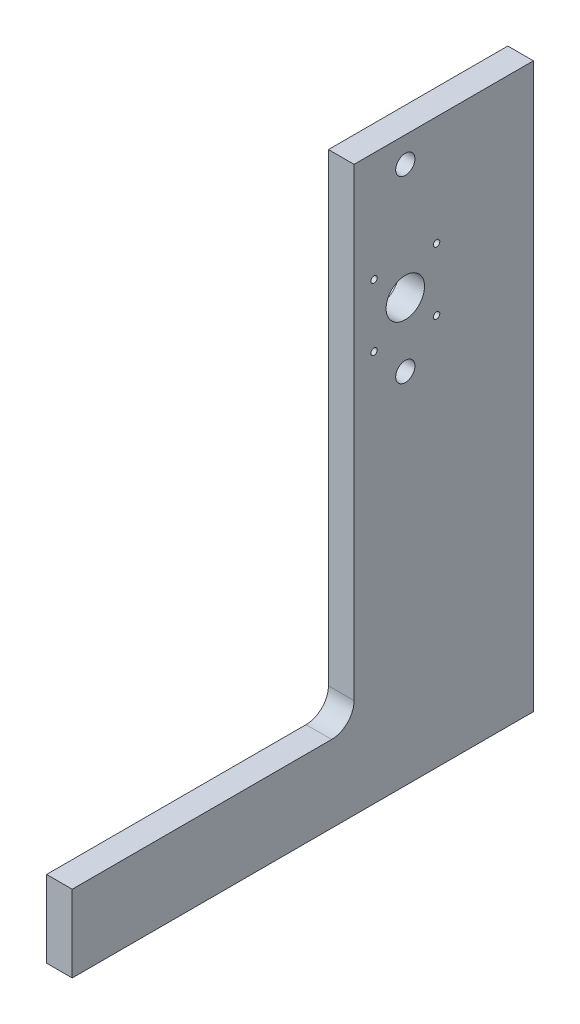
from build123d import *

# Parameters (mm, degrees)
SKETCH1_R           = 4.7625
SKETCH1_R_2         = 9.525
SKETCH1_R_3         = 1.5875
BOSS_EXTRUDE1_DEPTH = 12.7


with BuildPart() as part:
    # Sketch1 → Boss-Extrude1 (new body)
    with BuildSketch(Plane(origin=(0, 0, 0), x_dir=(0, 0, -1), z_dir=(1, 0, 0))):
        with BuildLine():
            Line((0, 0), (0, 38.1))
            Line((0, 38.1), (128.5875, 38.1))
            ThreePointArc((128.5875, 38.1), (136.445224106, 41.354775894), (139.7, 49.2125))
            Line((139.7, 49.2125), (139.7, 279.4))
            Line((139.7, 279.4), (228.6, 279.4))
            Line((228.6, 279.4), (228.6, 0))
            Line((228.6, 0), (0, 0))
        make_face()
        with Locations((165.1, 266.7)):
            Circle(SKETCH1_R, mode=Mode.SUBTRACT)
        with Locations((165.1, 177.8)):
            Circle(SKETCH1_R, mode=Mode.SUBTRACT)
        with Locations((165.1, 209.55)):
            Circle(SKETCH1_R_2, mode=Mode.SUBTRACT)
        with Locations((180.599999988, 225.049999988)):
            Circle(SKETCH1_R_3, mode=Mode.SUBTRACT)
        with Locations((149.611999988, 225.049999988)):
            Circle(SKETCH1_R_3, mode=Mode.SUBTRACT)
        with Locations((180.599999988, 194.061999988)):
            Circle(SKETCH1_R_3, mode=Mode.SUBTRACT)
        with Locations((149.611999988, 194.061999988)):
            Circle(SKETCH1_R_3, mode=Mode.SUBTRACT)
    extrude(amount=BOSS_EXTRUDE1_DEPTH)


solid = part.part
